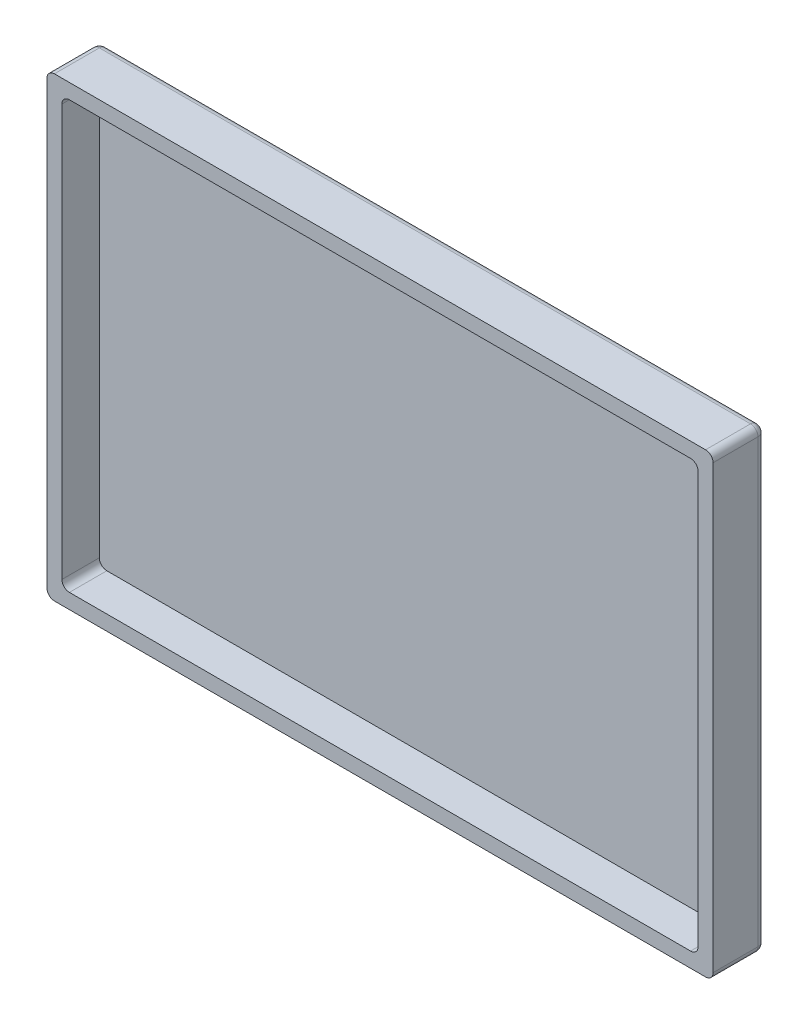
from build123d import *

# Parameters (mm, degrees)
ESBO_O1_W                = 89
ESBO_O1_H                = 61
ESBO_O1_W_2              = 85
ESBO_O1_H_2              = 57
RESSALTO_EXTRUS_O1_DEPTH = 5
ESBO_O2_W                = 89
ESBO_O2_H                = 61
RESSALTO_EXTRUS_O2_DEPTH = 2
FILETE6_R                = 1
FILETE7_R                = 1
FILETE10_R               = 1
FILETE11_R               = 1
FILETE12_R               = 1


with BuildPart() as part:
    # Esboço1 → Ressalto-extrusão1 (new body)
    with BuildSketch(Plane.XY):
        with Locations((-2.263340114, -16.201421801)):
            Rectangle(ESBO_O1_W, ESBO_O1_H)
        with Locations((-2.263340114, -16.201421801)):
            Rectangle(ESBO_O1_W_2, ESBO_O1_H_2, mode=Mode.SUBTRACT)
    extrude(amount=RESSALTO_EXTRUS_O1_DEPTH)

    # Esboço2 → Ressalto-extrusão2 (add)
    with BuildSketch(Plane(origin=(0, 0, 0), x_dir=(-1, 0, 0), z_dir=(0, 0, -1))):
        with Locations((2.263340114, -16.201421801)):
            Rectangle(ESBO_O2_W, ESBO_O2_H)
    extrude(amount=RESSALTO_EXTRUS_O2_DEPTH)

    # Filete6
    filete6_edges = [part.edges().sort_by_distance(p)[0] for p in [
        (40.236659886, 12.298578199, 2.5),
    ]]
    fillet(filete6_edges, radius=FILETE6_R)

    # Filete7
    filete7_edges = [part.edges().sort_by_distance(p)[0] for p in [
        (-44.763340114, 12.298578199, 2.5),
        (-44.763340114, -44.701421801, 2.5),
        (40.236659886, -44.701421801, 2.5),
    ]]
    fillet(filete7_edges, radius=FILETE7_R)

    # Filete10
    filete10_edges = [part.edges().sort_by_distance(p)[0] for p in [
        (-46.763340114, -46.701421801, 1.5),
    ]]
    fillet(filete10_edges, radius=FILETE10_R)

    # Filete11
    filete11_edges = [part.edges().sort_by_distance(p)[0] for p in [
        (-46.763340114, 14.298578199, 1.5),
        (42.236659886, 14.298578199, 1.5),
        (42.236659886, -46.701421801, 1.5),
    ]]
    fillet(filete11_edges, radius=FILETE11_R)

    # Filete12
    filete12_edges = [part.edges().sort_by_distance(p)[0] for p in [
        (-46.763340114, -16.201421801, -2),
        (-46.470446895, -46.408528582, -2),
        (42.236659886, -16.201421801, -2),
        (-2.263340114, -46.701421801, -2),
        (-2.263340114, 14.298578199, -2),
        (-46.470446895, 14.00568498, -2),
        (41.943766667, 14.00568498, -2),
        (41.943766667, -46.408528582, -2),
    ]]
    fillet(filete12_edges, radius=FILETE12_R)


solid = part.part
